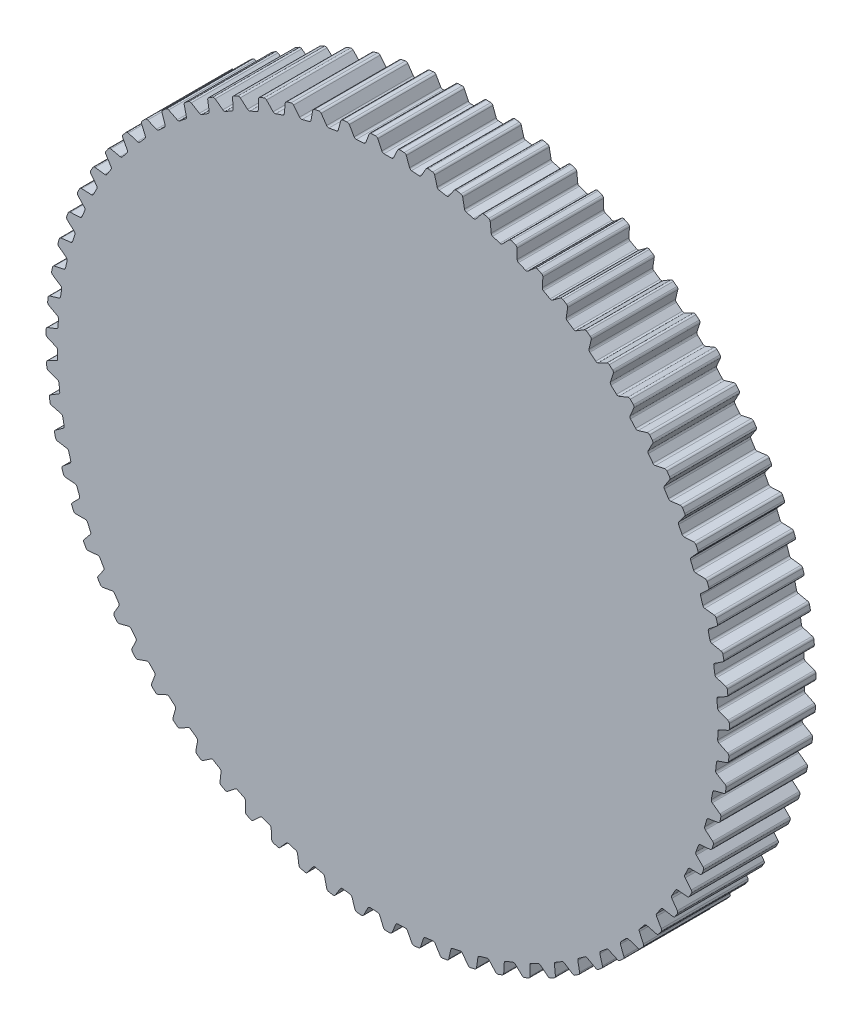
from build123d import *

# Parameters (mm, degrees)
SKIZZE1_R                       = 29.6
AUFSATZ_LINEAR_AUSTRAGEN1_DEPTH = 3.75
SKIZZE2_OUTSIDE_W               = 78.012
SKIZZE2_OUTSIDE_H               = 78.012
SCHNITT_LINEAR_AUSTRAGEN1_DEPTH = 43.527285359
KREISMUSTER3_COUNT              = 75


with BuildPart() as part:
    # Skizze1 → Aufsatz-Linear austragen1 (new, symmetric)
    with BuildSketch(Plane.XY):
        Circle(SKIZZE1_R)
    extrude(amount=AUFSATZ_LINEAR_AUSTRAGEN1_DEPTH, both=True)

    # Skizze2 outside → Schnitt-Linear austragen1 (cut, through all)
    with BuildSketch(Plane.XY.offset(3.75)):
        Rectangle(SKIZZE2_OUTSIDE_W, SKIZZE2_OUTSIDE_H)
        with BuildLine():
            Line((-0.859161547, 29.466108357), (-0.509136093, 28.715476348))
            ThreePointArc((-0.509136093, 28.715476348), (-0.435334457, 28.631321711), (-0.327874535, 28.6))
            Line((-0.327874535, 28.6), (0.327874535, 28.6))
            ThreePointArc((0.327874535, 28.6), (0.435334457, 28.631321711), (0.509136093, 28.715476348))
            Line((0.509136093, 28.715476348), (0.859161547, 29.466108357))
            ThreePointArc((0.859161547, 29.466108357), (0.935965118, 29.552138301), (1.047500813, 29.581459431))
            ThreePointArc((1.047500813, 29.581459431), (0, -29.6), (-1.047500813, 29.581459431))
            ThreePointArc((-1.047500813, 29.581459431), (-0.935965118, 29.552138301), (-0.859161547, 29.466108357))
        make_face(mode=Mode.SUBTRACT)
    schnitt_linear_austragen1 = extrude(amount=-SCHNITT_LINEAR_AUSTRAGEN1_DEPTH, mode=Mode.SUBTRACT)

    # Kreismuster3: Schnitt-Linear austragen1 ×75 about axis
    kreismuster3_axis = Axis((0, 0, 4.125), (0, 0, -1))
    for i in range(1, KREISMUSTER3_COUNT):
        add(schnitt_linear_austragen1.rotate(kreismuster3_axis, i * 360 / KREISMUSTER3_COUNT), mode=Mode.SUBTRACT)


solid = part.part
